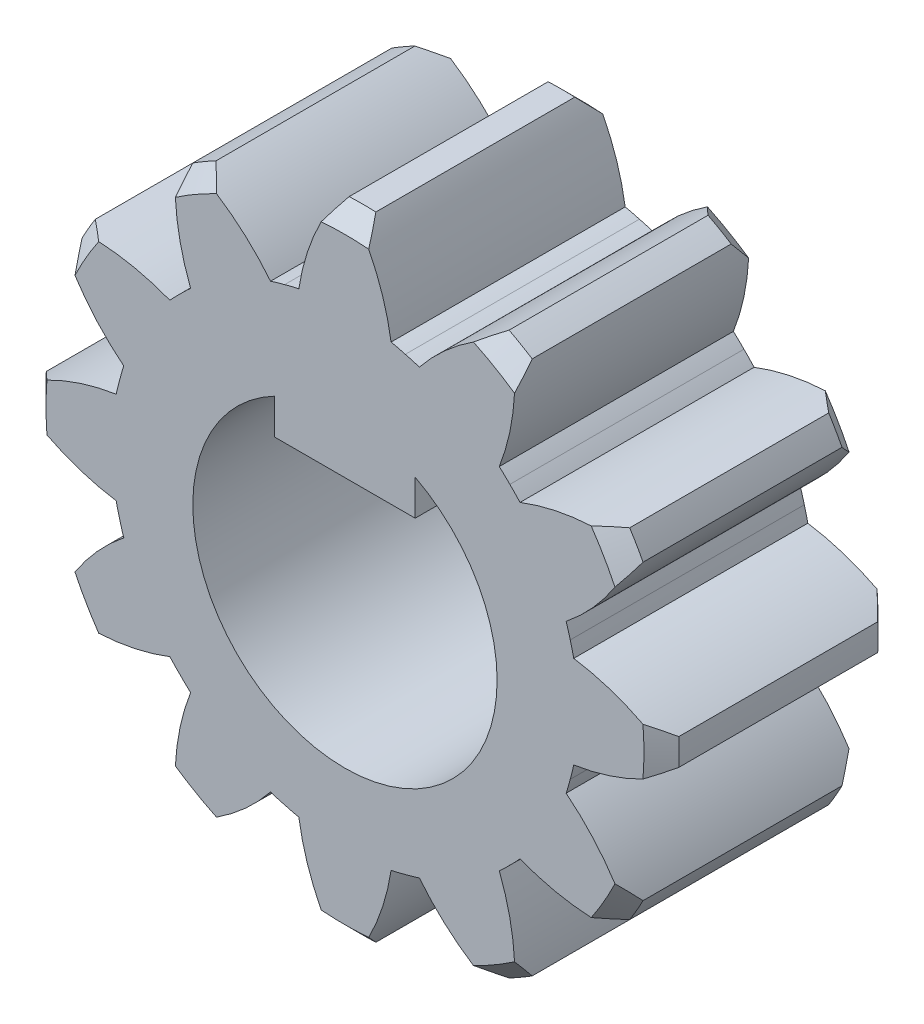
from build123d import *

# Parameters (mm, degrees)
BOSS_EXTRUDE1_DEPTH          = 10
CHAMFER1_SIZE                = 0.75
CIRPATTERN1_COUNT            = 12
CHAMFER1_OF_CIRPATTERN1_SIZE = 0.75
CUT_EXTRUDE2_DEPTH           = 10


with BuildPart() as part:
    # Sketch1 → Boss-Extrude1 (new body)
    with BuildSketch(Plane.XY):
        with BuildLine():
            ThreePointArc((-2.07, 9.271736623), (0, -9.5), (2.07, 9.271736623))
            ThreePointArc((2.07, 9.271736623), (1.625653209, 11.72726856), (0.57, 13.988391616))
            ThreePointArc((0.57, 13.988391616), (0, 14), (-0.57, 13.988391616))
            ThreePointArc((-0.57, 13.988391616), (-1.625653209, 11.72726856), (-2.07, 9.271736623))
        make_face()
    boss_extrude1 = extrude(amount=BOSS_EXTRUDE1_DEPTH)

    # Chamfer1
    chamfer1_edges = [part.edges().sort_by_distance(p)[0] for p in [
        (0, 14, 10),
        (0, 14, 0),
    ]]
    chamfer(chamfer1_edges, length=CHAMFER1_SIZE)

    # CirPattern1: Boss-Extrude1 ×12 about axis
    cirpattern1_axis = Axis((0, 0.479093936, 0), (0, 0, 1))
    for i in range(1, CIRPATTERN1_COUNT):
        add(boss_extrude1.rotate(cirpattern1_axis, i * 360 / CIRPATTERN1_COUNT))

    # Chamfer1 of CirPattern1
    chamfer1_of_cirpattern1_edges = [part.edges().sort_by_distance(p)[0] for p in [
        (-6.760453032, 12.18854207, 10),
        (-6.760453032, 12.18854207, 0),
        (-11.709448133, 7.239546968, 10),
        (-11.709448133, 7.239546968, 0),
        (-13.520906064, 0.479093936, 10),
        (-13.520906064, 0.479093936, 0),
        (-11.709448133, -6.281359096, 10),
        (-11.709448133, -6.281359096, 0),
        (-6.760453032, -11.230354197, 10),
        (-6.760453032, -11.230354197, 0),
        (0, -13.041812128, 10),
        (0, -13.041812128, 0),
        (6.760453032, -11.230354197, 10),
        (6.760453032, -11.230354197, 0),
        (11.709448133, -6.281359096, 10),
        (11.709448133, -6.281359096, 0),
        (13.520906064, 0.479093936, 10),
        (13.520906064, 0.479093936, 0),
        (11.709448133, 7.239546968, 10),
        (11.709448133, 7.239546968, 0),
        (6.760453032, 12.18854207, 10),
        (6.760453032, 12.18854207, 0),
    ]]
    chamfer(chamfer1_of_cirpattern1_edges, length=CHAMFER1_OF_CIRPATTERN1_SIZE)

    # Sketch3 → Cut-Extrude2 (cut)
    with BuildSketch(Plane.XY.offset(10)):
        with BuildLine():
            Line((-3, 4.25), (-3, 5.766281297))
            ThreePointArc((-3, 5.766281297), (-3.372684391, -5.556527693), (6.5, 0))
            ThreePointArc((6.5, 0), (5.556527693, 3.372684391), (3, 5.766281297))
            Line((3, 5.766281297), (3, 4.25))
            Line((3, 4.25), (-3, 4.25))
        make_face()
    extrude(amount=-CUT_EXTRUDE2_DEPTH, mode=Mode.SUBTRACT)


solid = part.part
